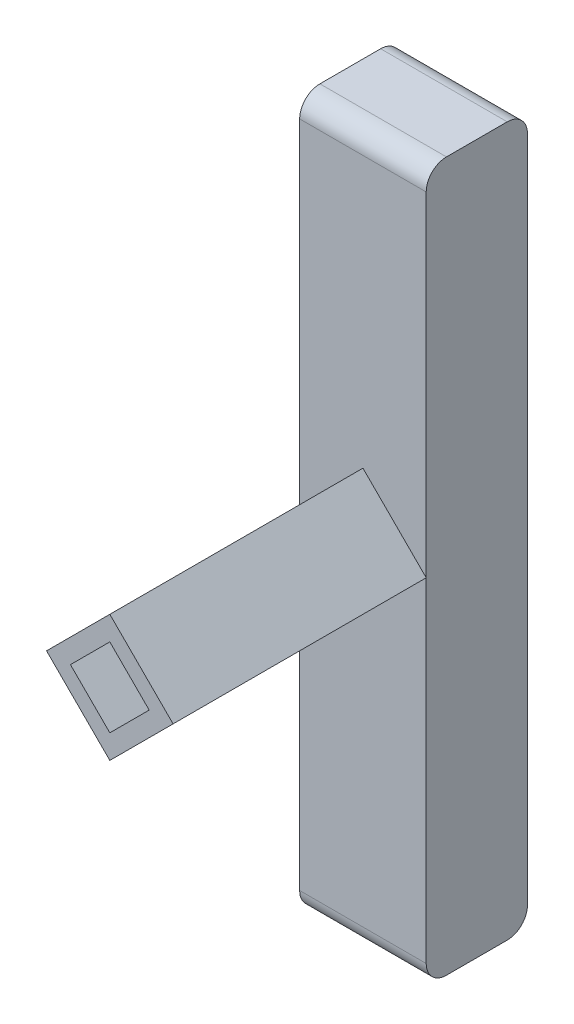
from build123d import *

# Parameters (mm, degrees)
ESQUISSE1_W             = 12.5
ESQUISSE1_H             = 70
BOSS_EXTRU_1_DEPTH      = 10
BOSS_EXTRU_2_DEPTH      = 35
ENL_V_MAT_EXTRU_1_DEPTH = 40
CONG_3_R                = 2


with BuildPart() as part:
    # Esquisse1 → Boss.-Extru.1 (new body)
    with BuildSketch(Plane.XY):
        Rectangle(ESQUISSE1_W, ESQUISSE1_H)
    extrude(amount=BOSS_EXTRU_1_DEPTH)

    # Esquisse2 → Boss.-Extru.2 (add)
    with BuildSketch(Plane(origin=(0, 0, 0), x_dir=(-1, 0, 0), z_dir=(0, 0, -1))):
        Polygon((6.25, 0), (0, 6.25), (-6.25, 0), (0, -6.25), align=None)
    extrude(amount=-BOSS_EXTRU_2_DEPTH)

    # Esquisse3 → Enlèv. mat.-Extru.1 (cut)
    with BuildSketch(Plane(origin=(0, 0, 0), x_dir=(-1, 0, 0), z_dir=(0, 0, -1))):
        Polygon((-3.889087297, 0), (0, 3.889087297), (3.889087297, 0), (0, -3.889087297), align=None)
    extrude(amount=-ENL_V_MAT_EXTRU_1_DEPTH, mode=Mode.SUBTRACT)

    # Congé3
    cong_3_edges = [part.edges().sort_by_distance(p)[0] for p in [
        (0, -35, 10),
        (0, -35, 0),
        (0, 35, 0),
        (0, 35, 10),
    ]]
    fillet(cong_3_edges, radius=CONG_3_R)


solid = part.part
